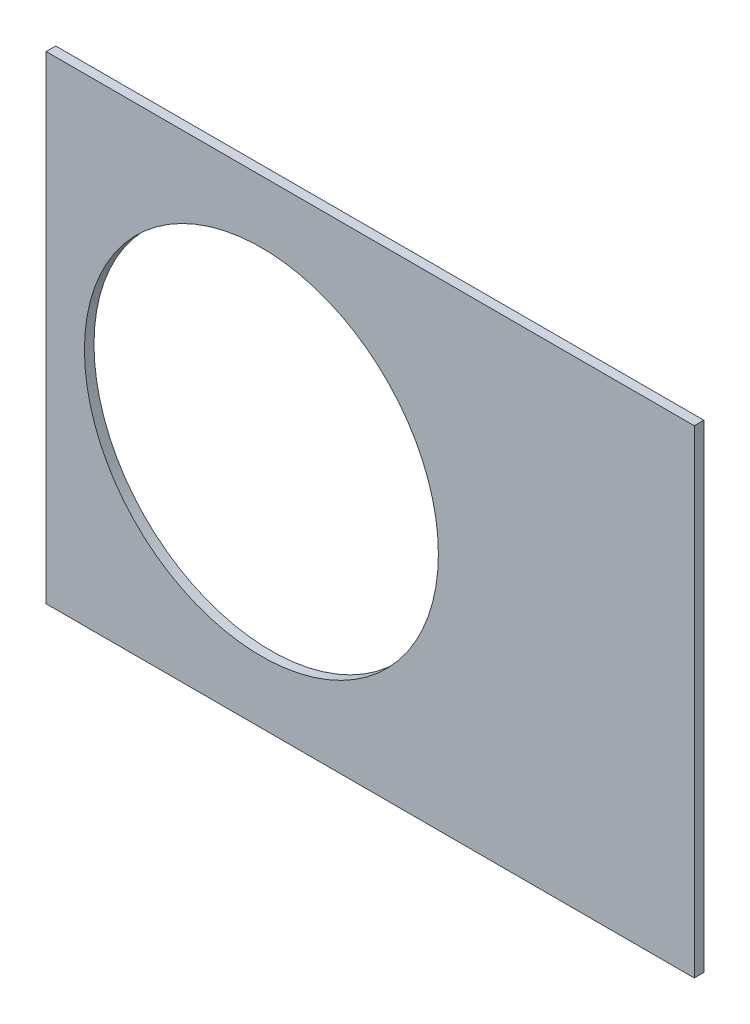
from build123d import *

# Parameters (mm, degrees)
BOSS_EXTRUDE1_DEPTH = 0.254
SKETCH2_R           = 4.699
CUT_EXTRUDE1_DEPTH  = 1.254
SKETCH3_W           = 2.54
SKETCH3_H           = 0.635
CUT_EXTRUDE2_DEPTH  = 1.254
SKETCH5_OUTSIDE_W   = 121.447
SKETCH5_OUTSIDE_H   = 109.618
SKETCH5_OUTSIDE_W_2 = 17.2085
SKETCH5_OUTSIDE_H_2 = 15.24
CUT_EXTRUDE5_DEPTH  = 1.254


with BuildPart() as part:
    # Sketch1 → Boss-Extrude1 (new body)
    with BuildSketch(Plane.XY):
        with BuildLine():
            Line((67.21146711, 76.191723231), (8.696654013, 17.676910134))
            Line((8.696654013, 17.676910134), (7.228954972, 14.133571205))
            ThreePointArc((7.228954972, 14.133571205), (14.666587579, 6.075099489), (15.105587123, -4.88230096))
            Line((15.105587123, -4.88230096), (18.648926052, -6.35))
            Line((18.648926052, -6.35), (101.401368334, -6.35))
            ThreePointArc((101.401368334, -6.35), (93.866160503, 38.880636728), (67.21146711, 76.191723231))
        make_face()
        with BuildLine():
            Line((88.672924278, 6.35), (27.86051193, 6.35))
            ThreePointArc((27.86051193, 6.35), (26.399857642, 10.93517908), (24.190484974, 15.210228852))
            Line((24.190484974, 15.210228852), (67.191354125, 58.211098004))
            ThreePointArc((67.191354125, 58.211098004), (82.13289044, 34.020557137), (88.672924278, 6.35))
        make_face(mode=Mode.SUBTRACT)
    extrude(amount=BOSS_EXTRUDE1_DEPTH)

    # Sketch2 → Cut-Extrude1 (cut, through all)
    with BuildSketch(Plane.XY.offset(0.254)):
        with Locations((22.225, 0)):
            Circle(SKETCH2_R)
        with Locations((36.195, 0)):
            Circle(SKETCH2_R)
        with Locations((61.722, 0)):
            Circle(SKETCH2_R)
        with Locations((75.692, 0)):
            Circle(SKETCH2_R)
        with Locations((95.25, 0)):
            Circle(SKETCH2_R)
        with Locations((15.715448212, 15.715448212)):
            Circle(SKETCH2_R)
        with Locations((25.593729945, 25.593729945)):
            Circle(SKETCH2_R)
        with Locations((43.644044748, 43.644044748)):
            Circle(SKETCH2_R)
        with Locations((53.522326482, 53.522326482)):
            Circle(SKETCH2_R)
        with Locations((92.004434954, 24.652514046)):
            Circle(SKETCH2_R)
        with Locations((82.48891971, 47.625)):
            Circle(SKETCH2_R)
        with Locations((67.351920908, 67.351920908)):
            Circle(SKETCH2_R)
    extrude(amount=-CUT_EXTRUDE1_DEPTH, mode=Mode.SUBTRACT)

    # Sketch3 → Cut-Extrude2 (cut, through all)
    with BuildSketch(Plane.XY.offset(0.254)):
        Polygon((15.266435406, 24.246691527), (17.06248663, 26.042742751), (17.511499436, 25.593729945), (15.715448212, 23.797678721), align=None)
        Polygon((44.991083167, 53.971339288), (43.195031942, 52.175288063), (43.644044748, 51.726275257), (45.440095973, 53.522326482), align=None)
        with Locations((29.21, -6.0325)):
            Rectangle(SKETCH3_W, SKETCH3_H)
        with Locations((68.707, -6.0325)):
            Rectangle(SKETCH3_W, SKETCH3_H)
        Polygon((29.230733674, 38.210989795), (31.026784898, 40.007041019), (31.475797704, 39.558028213), (29.67974648, 37.761976989), align=None)
        Polygon((56.845021246, 65.825277367), (55.048970022, 64.029226143), (55.497982828, 63.580213337), (57.294034052, 65.376264561), align=None)
        with Locations((48.9585, -6.0325)):
            Rectangle(SKETCH3_W, SKETCH3_H)
        with Locations((85.471, -6.0325)):
            Rectangle(SKETCH3_W, SKETCH3_H)
        Polygon((99.935462164, 14.437711971), (100.266998693, 11.919442024), (101.526133667, 12.085210288), (101.194597138, 14.603480236), align=None)
        Polygon((93.765504959, 37.464305742), (94.938831965, 37.950313702), (93.966816047, 40.296967714), (92.793489041, 39.810959755), align=None)
        Polygon((79.327792988, 62.471156422), (80.874047017, 60.456038938), (81.88160576, 61.229165953), (80.33535173, 63.244283437), align=None)
        Polygon((13.593916116, 7.005422516), (14.565932035, 4.658768503), (15.739259041, 5.144776462), (14.767243123, 7.491430475), align=None)
    extrude(amount=-CUT_EXTRUDE2_DEPTH, mode=Mode.SUBTRACT)

    # Sketch5 outside → Cut-Extrude5 (cut, through all)
    with BuildSketch(Plane.XY.offset(0.254)):
        with Locations((54.4145, 34.921)):
            Rectangle(SKETCH5_OUTSIDE_W, SKETCH5_OUTSIDE_H)
        with Locations((39.08425, 0)):
            Rectangle(SKETCH5_OUTSIDE_W_2, SKETCH5_OUTSIDE_H_2, mode=Mode.SUBTRACT)
    extrude(amount=-CUT_EXTRUDE5_DEPTH, mode=Mode.SUBTRACT)


solid = part.part
